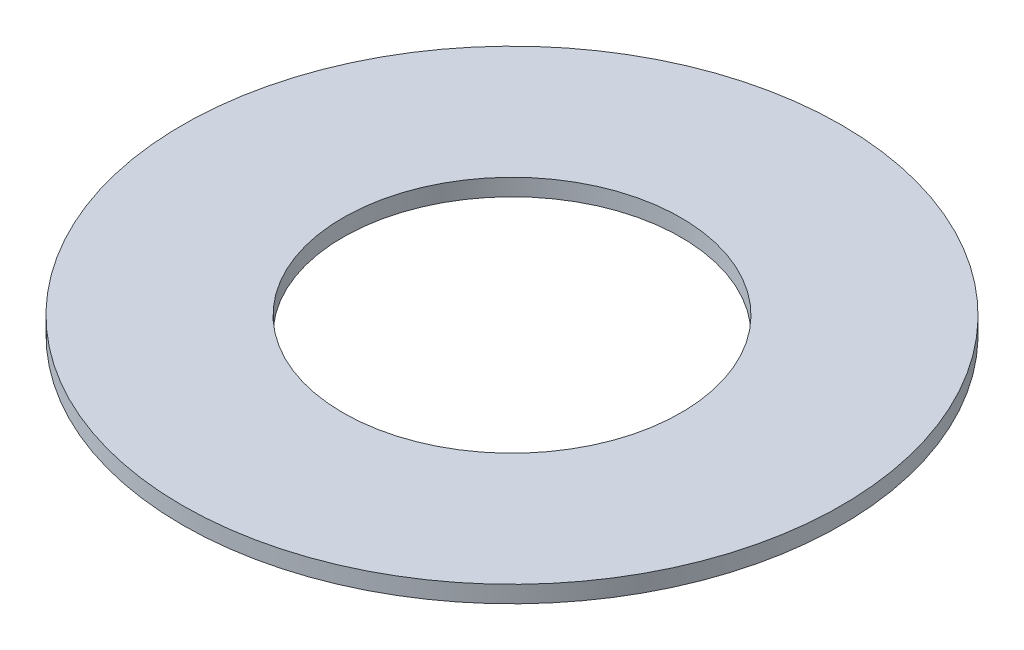
from build123d import *

# Parameters (mm, degrees)
SKETCH1_R           = 9.75
SKETCH1_R_2         = 5
BOSS_EXTRUDE1_DEPTH = 0.5


with BuildPart() as part:
    # Sketch1 → Boss-Extrude1 (new body)
    with BuildSketch(Plane(origin=(0, 0, 0), x_dir=(1, 0, 0), z_dir=(0, 1, 0))):
        Circle(SKETCH1_R)
        Circle(SKETCH1_R_2, mode=Mode.SUBTRACT)
    extrude(amount=BOSS_EXTRUDE1_DEPTH)


solid = part.part
